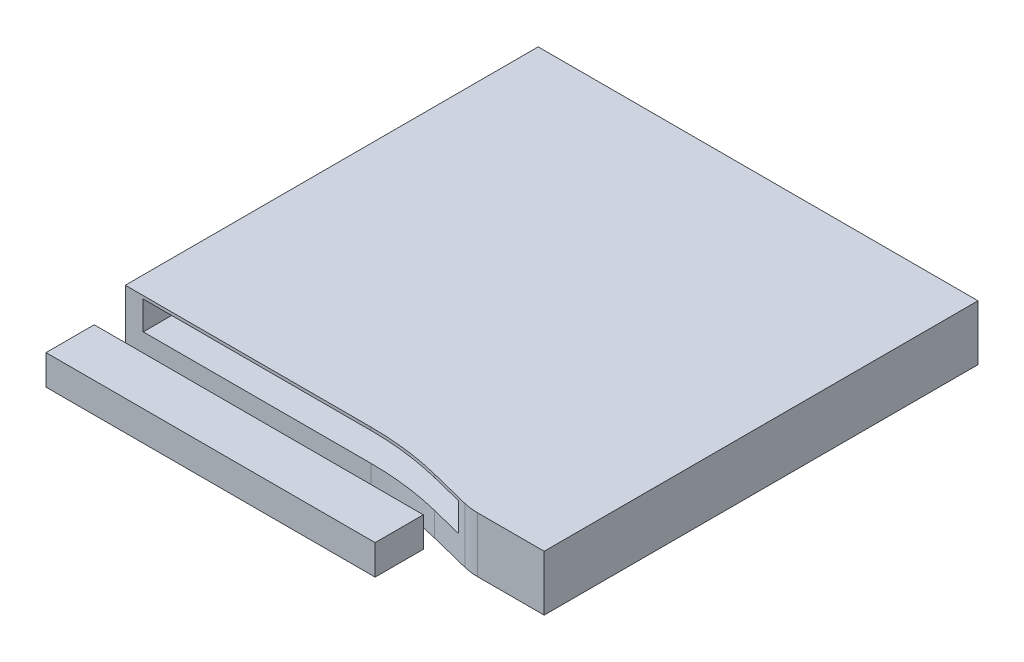
from build123d import *

# Parameters (mm, degrees)
EXTRUDE_1_DEPTH      = 1.85
SKETCH_2_R           = 0.4
EXTRUDE_2_DEPTH      = 0.59
SKETCH_3_W           = 0.3
SKETCH_3_H           = 0.1
EXTRUDE_3_DEPTH      = 0.5
EXTRUDE_3_2_DEPTH    = 0.5
EXTRUDE_3_3_DEPTH    = 0.5
EXTRUDE_3_4_DEPTH    = 0.5
EXTRUDE_3_5_DEPTH    = 0.5
EXTRUDE_3_6_DEPTH    = 0.5
EXTRUDE_3_7_DEPTH    = 0.5
EXTRUDE_3_8_DEPTH    = 0.5
EXTRUDE_3_9_DEPTH    = 0.5
SKETCH_4_W           = 11.1
SKETCH_4_H           = 0.95
CUT_EXTRUDE_1_DEPTH  = 14
EXTRUDE_START        = -0.575
SKETCH_5_W           = 11
SKETCH_5_H           = 1.611144306
EXTRUDE_4_DEPTH      = 0.6
EXTRUDE_4_DEPTH_BACK = 0.4


with BuildPart() as part:
    # 草图1 → 凸台-拉伸1 (new body)
    with BuildSketch(Plane(origin=(0, 0, 0), x_dir=(1, 0, 0), z_dir=(0, 1, 0))):
        with BuildLine():
            Line((0, -13.8), (8.206702303, -13.8))
            ThreePointArc((8.206702303, -13.8), (9.432369379, -13.875397226), (10.639554075, -14.100451956))
            Line((10.639554075, -14.100451956), (11.992939368, -14.439909609))
            ThreePointArc((11.992939368, -14.439909609), (12.234376307, -14.484920555), (12.479509723, -14.5))
            Line((12.479509723, -14.5), (14.7, -14.5))
            Line((14.7, -14.5), (14.7, 0))
            Line((14.7, 0), (0, 0))
            Line((0, 0), (0, -13.8))
        make_face()
    extrude(amount=EXTRUDE_1_DEPTH)

    # 草图2 → 凸台-拉伸2 (add)
    with BuildSketch(Plane.XZ):
        with Locations((2.4, 10.5)):
            Circle(SKETCH_2_R)
        with Locations((10.4, 10.5)):
            Circle(SKETCH_2_R)
    extrude(amount=EXTRUDE_2_DEPTH)

    # 草图4 → 切除-拉伸1 (cut)
    with BuildSketch(Plane.XY.offset(14.5)):
        with Locations((6.15, 1.275)):
            Rectangle(SKETCH_4_W, SKETCH_4_H)
    extrude(amount=-CUT_EXTRUDE_1_DEPTH, mode=Mode.SUBTRACT)


with BuildPart() as body_2:
    # 草图3 → 凸台-拉伸3 (new body)
    with BuildSketch(Plane(origin=(0, 0, 0), x_dir=(-1, 0, 0), z_dir=(0, 0, -1))):
        with Locations((-9.6, 0.05)):
            Rectangle(SKETCH_3_W, SKETCH_3_H)
    extrude(amount=EXTRUDE_3_DEPTH)


with BuildPart() as body_3:
    # 草图3 → Extrude 3 2 (new body)
    with BuildSketch(Plane(origin=(0, 0, 0), x_dir=(-1, 0, 0), z_dir=(0, 0, -1))):
        with Locations((-8.5, 0.05)):
            Rectangle(SKETCH_3_W, SKETCH_3_H)
    extrude(amount=EXTRUDE_3_2_DEPTH)


with BuildPart() as body_4:
    # 草图3 → Extrude 3 3 (new body)
    with BuildSketch(Plane(origin=(0, 0, 0), x_dir=(-1, 0, 0), z_dir=(0, 0, -1))):
        with Locations((-7.4, 0.05)):
            Rectangle(SKETCH_3_W, SKETCH_3_H)
    extrude(amount=EXTRUDE_3_3_DEPTH)


with BuildPart() as body_5:
    # 草图3 → Extrude 3 4 (new body)
    with BuildSketch(Plane(origin=(0, 0, 0), x_dir=(-1, 0, 0), z_dir=(0, 0, -1))):
        with Locations((-6.3, 0.05)):
            Rectangle(SKETCH_3_W, SKETCH_3_H)
    extrude(amount=EXTRUDE_3_4_DEPTH)


with BuildPart() as body_6:
    # 草图3 → Extrude 3 5 (new body)
    with BuildSketch(Plane(origin=(0, 0, 0), x_dir=(-1, 0, 0), z_dir=(0, 0, -1))):
        with Locations((-5.2, 0.05)):
            Rectangle(SKETCH_3_W, SKETCH_3_H)
    extrude(amount=EXTRUDE_3_5_DEPTH)


with BuildPart() as body_7:
    # 草图3 → Extrude 3 6 (new body)
    with BuildSketch(Plane(origin=(0, 0, 0), x_dir=(-1, 0, 0), z_dir=(0, 0, -1))):
        with Locations((-4.1, 0.05)):
            Rectangle(SKETCH_3_W, SKETCH_3_H)
    extrude(amount=EXTRUDE_3_6_DEPTH)


with BuildPart() as body_8:
    # 草图3 → Extrude 3 7 (new body)
    with BuildSketch(Plane(origin=(0, 0, 0), x_dir=(-1, 0, 0), z_dir=(0, 0, -1))):
        with Locations((-3, 0.05)):
            Rectangle(SKETCH_3_W, SKETCH_3_H)
    extrude(amount=EXTRUDE_3_7_DEPTH)


with BuildPart() as body_9:
    # 草图3 → Extrude 3 8 (new body)
    with BuildSketch(Plane(origin=(0, 0, 0), x_dir=(-1, 0, 0), z_dir=(0, 0, -1))):
        with Locations((-1.9, 0.05)):
            Rectangle(SKETCH_3_W, SKETCH_3_H)
    extrude(amount=EXTRUDE_3_8_DEPTH)


with BuildPart() as body_10:
    # 草图3 → Extrude 3 9 (new body)
    with BuildSketch(Plane(origin=(0, 0, 0), x_dir=(-1, 0, 0), z_dir=(0, 0, -1))):
        with Locations((-0.8, 0.05)):
            Rectangle(SKETCH_3_W, SKETCH_3_H)
    extrude(amount=EXTRUDE_3_9_DEPTH)


with BuildPart() as body_11:
    # 草图5 → 凸台-拉伸4 (new body, two sides)
    with BuildSketch(Plane(origin=(0, 1.85, 0), x_dir=(1, 0, 0), z_dir=(0, 1, 0)).offset(EXTRUDE_START)) as extrude_4_sk:
        with Locations((6.15, -16.294427847)):
            Rectangle(SKETCH_5_W, SKETCH_5_H)
    extrude(amount=EXTRUDE_4_DEPTH)
    extrude(extrude_4_sk.sketch, amount=-EXTRUDE_4_DEPTH_BACK)


solid = Compound([part.part, body_2.part, body_3.part, body_4.part, body_5.part, body_6.part, body_7.part, body_8.part, body_9.part, body_10.part, body_11.part])
